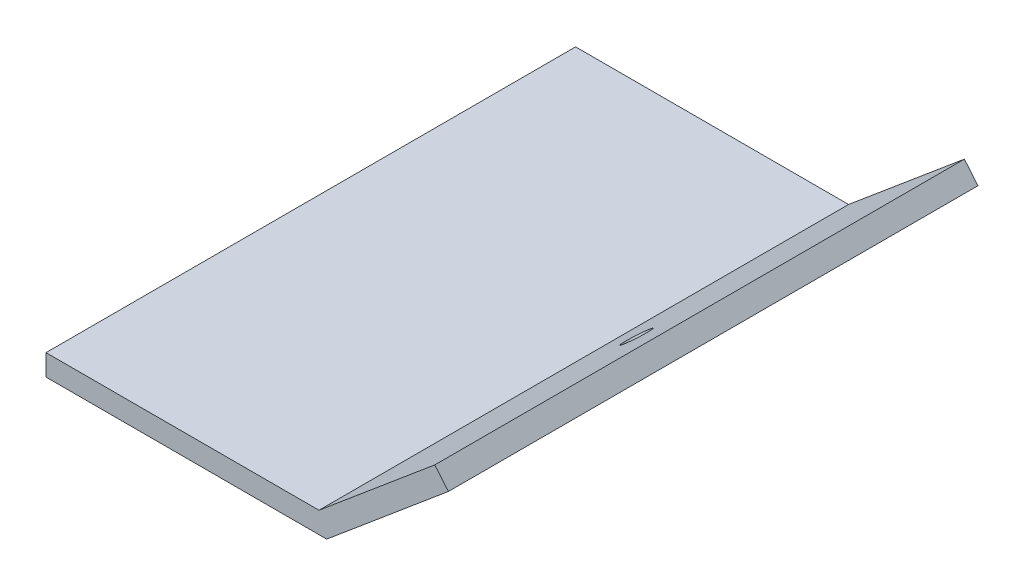
from build123d import *

# Parameters (mm, degrees)
EXTRUDE_1_DEPTH = 50
M3X0_5_1_D      = 2.5
M3X0_5_1_DEPTH  = 8.5
M3X0_5_1_TIP    = 0.751075774


with BuildPart() as part:
    # ｽｹｯﾁ1 → ﾎﾞｽ - 押し出し1 (new body)
    with BuildSketch(Plane.XY):
        Polygon((0, 0), (25.772059531, 0), (36.705091427, 9.173903032), (37.990666647, 7.641814145), (26.5, -2), (0, -2), align=None)
    extrude(amount=EXTRUDE_1_DEPTH)

    # M3x0.5 ねじ穴1
    with Locations(Plane(origin=(30.751348412, 4.178119463, 25), x_dir=(0.766044443, 0.64278761, 0), z_dir=(-0.64278761, 0.766044443, 0))):
        with Locations((0, 0)):
            Hole(M3X0_5_1_D / 2, depth=M3X0_5_1_DEPTH)
            with Locations((0, 0, -(M3X0_5_1_DEPTH + M3X0_5_1_TIP / 2))):  # 118° drill point
                Cone(0, M3X0_5_1_D / 2, M3X0_5_1_TIP, mode=Mode.SUBTRACT)


solid = part.part
